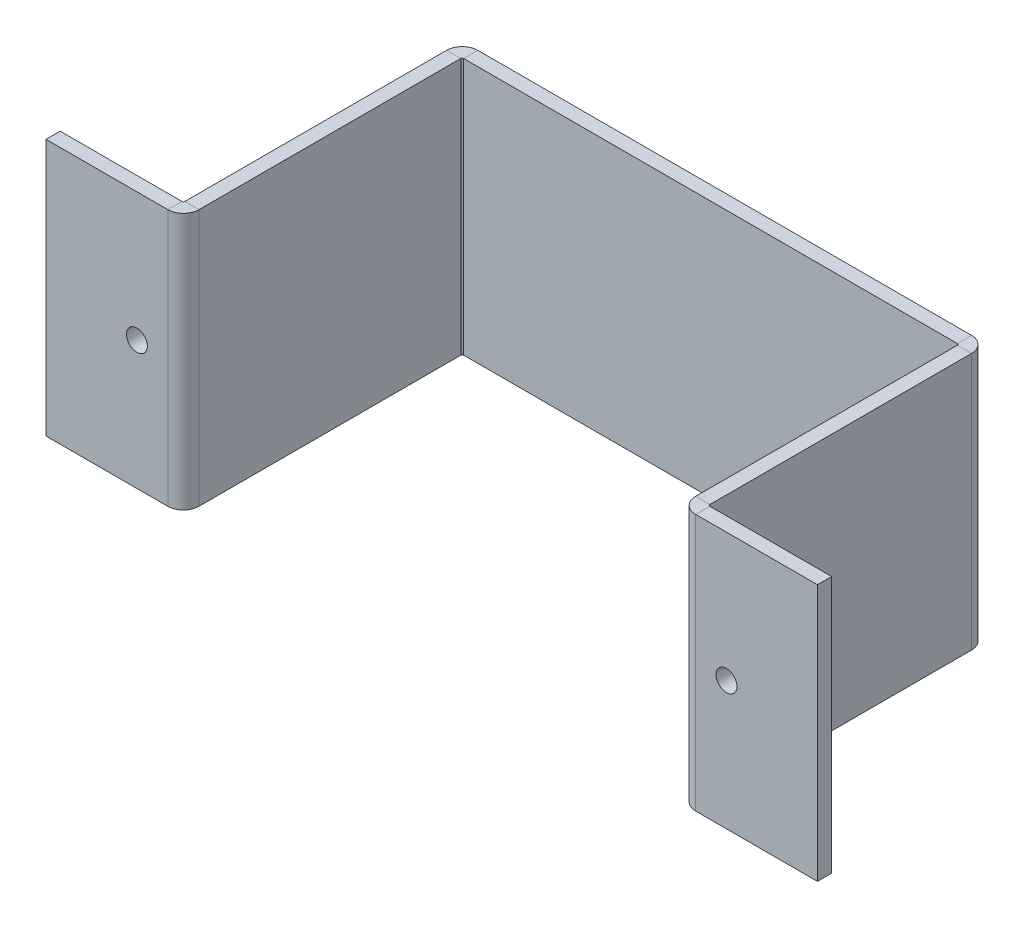
from build123d import *

# Parameters (mm, degrees)
SKETCH2_W           = 1.66
SKETCH2_H           = 30.07
SKETCH3_R           = 1.225
CUT_EXTRUDE1_DEPTH  = 58.692180796
BOSS_EXTRUDE1_START = 1.43
SKETCH3_3_R         = 3.175
SKETCH3_3_R_2       = 1.225
BOSS_EXTRUDE1_DEPTH = 1.43


with BuildPart() as part:
    # Sweep1: sweep along a path in Sketch1
    with BuildLine(Plane(origin=(0, 0, 0), x_dir=(1, 0, 0), z_dir=(0, 1, 0))) as sweep1_path:
        Line((-45.14, 0), (-30.89, 0))
        ThreePointArc((-30.89, 0), (-30.182893219, 0.292893219), (-29.89, 1))
        Line((-29.89, 1), (-29.89, 31.63))
        ThreePointArc((-29.89, 31.63), (-29.597106781, 32.337106781), (-28.89, 32.63))
        Line((-28.89, 32.63), (28.89, 32.63))
        ThreePointArc((28.89, 32.63), (29.597106781, 32.337106781), (29.89, 31.63))
        Line((29.89, 31.63), (29.89, 1))
        ThreePointArc((29.89, 1), (30.182893219, 0.292893219), (30.89, 0))
        Line((30.89, 0), (45.14, 0))
    # Sketch2 → Sweep1 (sweep)
    with BuildSketch(Plane(origin=(45.14, 0, 0), x_dir=(0, 0, -1), z_dir=(1, 0, 0))):
        Rectangle(SKETCH2_W, SKETCH2_H)
    sweep(path=sweep1_path.line)

    # Sketch3 → Cut-Extrude1 (cut, through all)
    with BuildSketch(Plane(origin=(0, 0, -0.83), x_dir=(-1, 0, 0), z_dir=(0, 0, -1))):
        with Locations((-34.5, 0)):
            Circle(SKETCH3_R)
    cut_extrude1 = extrude(amount=-CUT_EXTRUDE1_DEPTH, mode=Mode.SUBTRACT)

    # Sketch3_3 → Boss-Extrude1 (add)
    with BuildSketch(Plane(origin=(0, 0, -0.83), x_dir=(-1, 0, 0), z_dir=(0, 0, -1)).offset(BOSS_EXTRUDE1_START)):
        with Locations((-34.5, 0)):
            Circle(SKETCH3_3_R)
        with Locations((-34.5, 0)):
            Circle(SKETCH3_3_R_2, mode=Mode.SUBTRACT)
    boss_extrude1 = extrude(amount=-BOSS_EXTRUDE1_DEPTH)

    # Mirror1: Cut-Extrude1, Boss-Extrude1 across plane
    add(cut_extrude1.mirror(Plane(origin=(0, 0, 0), x_dir=(0, 0, 1), z_dir=(1, 0, 0))), mode=Mode.SUBTRACT)
    add(boss_extrude1.mirror(Plane(origin=(0, 0, 0), x_dir=(0, 0, 1), z_dir=(1, 0, 0))))


solid = part.part
